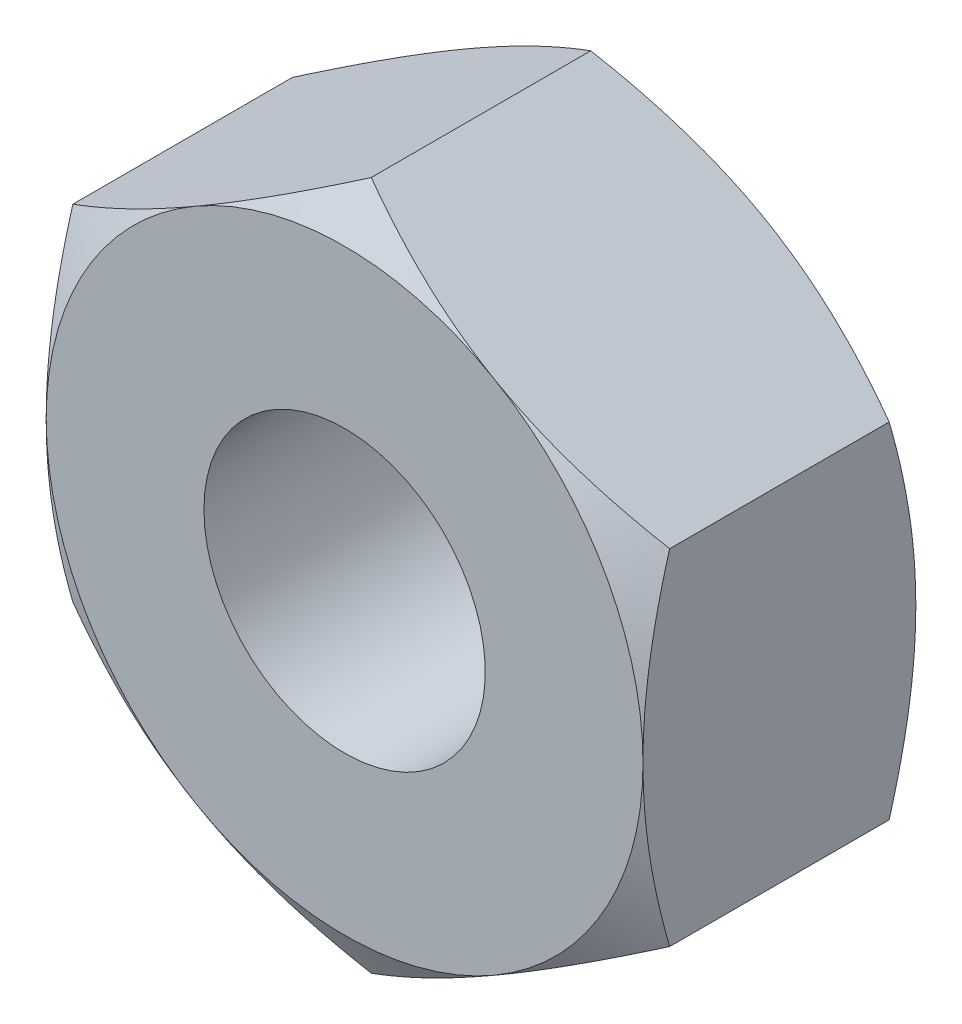
from build123d import *

# Parameters (mm, degrees)
BASE_EXTRUSION_DEPTH  = 3.2
TROU_TARAUD_M41_D     = 3.3
TROU_TARAUD_M41_DEPTH = 3.2


with BuildPart() as part:
    # Esquisse1 → Base-Extrusion (new body)
    with BuildSketch(Plane.XY):
        Polygon((3.5, -2.020725942), (3.5, 2.020725942), (0, 4.041451884), (-3.5, 2.020725942), (-3.5, -2.020725942), (0, -4.041451884), align=None)
    extrude(amount=-BASE_EXTRUSION_DEPTH)

    # Esquisse2 → Enlèvement de matière-Révolution1 (revolve, cut)
    with BuildSketch(Plane(origin=(0, 0, 0), x_dir=(1, 0, 0), z_dir=(0, 1, 0))):
        Polygon((-3.5, 0), (-7.271281292, 0), (-7.271281292, 3.2), (-3.5, 3.2), (-6.271281292, 1.6), align=None)
    revolve(axis=Axis((0, 0, -3.2), (0, 0, 1)), mode=Mode.SUBTRACT)

    # Trou taraudé M41
    with Locations(Plane(origin=(0, 0, -3.2), x_dir=(-1, 0, 0), z_dir=(0, 0, -1))):
        with Locations((0, 0)):
            Hole(TROU_TARAUD_M41_D / 2, depth=TROU_TARAUD_M41_DEPTH)


solid = part.part
